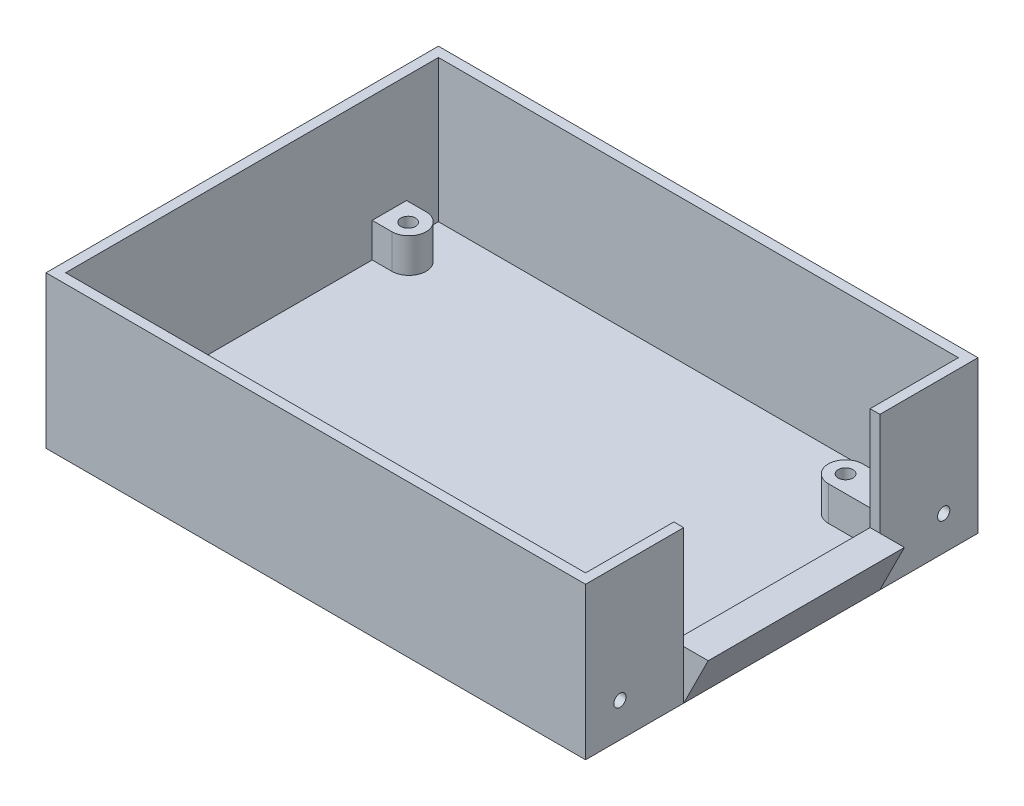
from build123d import *

# Parameters (mm, degrees)
SKETCH5_W            = 110
SKETCH5_H            = 80
BOSS_EXTRUDE8_DEPTH  = 2
SKETCH9_R            = 3.5
BOSS_EXTRUDE11_DEPTH = 7
SKETCH11_R           = 1.5
CUT_EXTRUDE1_DEPTH   = 7
SKETCH12_W           = 110
SKETCH12_H           = 80
SKETCH12_W_2         = 106
SKETCH12_H_2         = 76
BOSS_EXTRUDE12_DEPTH = 29
BOSS_EXTRUDE14_DEPTH = 7
BOSS_EXTRUDE15_DEPTH = 7
CUT_EXTRUDE2_REACH   = 112
SKETCH16_W           = 40
SKETCH16_H           = 21
BOSS_EXTRUDE16_DEPTH = 7
BOSS_EXTRUDE17_DEPTH = 7
BOSS_EXTRUDE18_DEPTH = 40
CUT_EXTRUDE4_REACH   = 112
SKETCH23_R           = 1.25
CUT_EXTRUDE5_REACH   = 112
SKETCH24_R           = 1.25


with BuildPart() as part:
    # Sketch5 → Boss-Extrude8 (new body)
    with BuildSketch(Plane(origin=(0, 0, 0), x_dir=(1, 0, 0), z_dir=(0, 1, 0))):
        with Locations((-25, 43.57615894)):
            Rectangle(SKETCH5_W, SKETCH5_H)
    extrude(amount=BOSS_EXTRUDE8_DEPTH)

    # Sketch9 → Boss-Extrude11 (add)
    with BuildSketch(Plane(origin=(0, 2, 0), x_dir=(1, 0, 0), z_dir=(0, 1, 0))):
        with Locations((-74, 15.57615894)):
            Circle(SKETCH9_R)
        with Locations((-74, 71.57615894)):
            Circle(SKETCH9_R)
        with Locations((15, 15.57615894)):
            Circle(SKETCH9_R)
        with Locations((15, 71.57615894)):
            Circle(SKETCH9_R)
    extrude(amount=BOSS_EXTRUDE11_DEPTH)

    # Sketch11 → Cut-Extrude1 (cut)
    with BuildSketch(Plane(origin=(0, 9, 0), x_dir=(1, 0, 0), z_dir=(0, 1, 0))):
        with Locations((-74, 15.57615894)):
            Circle(SKETCH11_R)
        with Locations((-74, 71.405276361)):
            Circle(SKETCH11_R)
        with Locations((15, 71.57615894)):
            Circle(SKETCH11_R)
        with Locations((15, 15.57615894)):
            Circle(SKETCH11_R)
    extrude(amount=-CUT_EXTRUDE1_DEPTH, mode=Mode.SUBTRACT)

    # Sketch12 → Boss-Extrude12 (add)
    with BuildSketch(Plane(origin=(0, 2, 0), x_dir=(1, 0, 0), z_dir=(0, 1, 0))):
        with Locations((-25, 43.57615894)):
            Rectangle(SKETCH12_W, SKETCH12_H)
        with Locations((-25, 43.57615894)):
            Rectangle(SKETCH12_W_2, SKETCH12_H_2, mode=Mode.SUBTRACT)
    extrude(amount=BOSS_EXTRUDE12_DEPTH)

    # Sketch14 → Boss-Extrude14 (add)
    with BuildSketch(Plane(origin=(0, 2, 0), x_dir=(1, 0, 0), z_dir=(0, 1, 0))):
        Polygon((-74, 12.07615894), (-78, 12.07615894), (-78, 19.07615894), (-74, 19.07615894), (-77.5, 15.57615894), align=None)
    extrude(amount=BOSS_EXTRUDE14_DEPTH)

    # Sketch15 → Boss-Extrude15 (add)
    with BuildSketch(Plane(origin=(0, 2, 0), x_dir=(1, 0, 0), z_dir=(0, 1, 0))):
        Polygon((-74, 75.07615894), (-78, 75.07615894), (-78, 68.07615894), (-74, 68.07615894), (-77.5, 71.57615894), align=None)
    extrude(amount=BOSS_EXTRUDE15_DEPTH)

    # Sketch16 → Cut-Extrude2 (cut, up to next)
    with BuildSketch(Plane(origin=(30, 0, 0), x_dir=(0, 0, -1), z_dir=(1, 0, 0)), mode=Mode.PRIVATE) as cut_extrude2_sk1:
        with Locations((43.57615894, 20.5)):
            Rectangle(SKETCH16_W, SKETCH16_H)
    cut_extrude2_tool1 = extrude(cut_extrude2_sk1.sketch, amount=-CUT_EXTRUDE2_REACH, mode=Mode.PRIVATE) & part.part
    add(cut_extrude2_tool1.solids().sort_by_distance((30, 20.5, -43.576159))[0], mode=Mode.SUBTRACT)

    # Sketch17 → Boss-Extrude16 (add)
    with BuildSketch(Plane(origin=(0, 2, 0), x_dir=(1, 0, 0), z_dir=(0, 1, 0))):
        Polygon((15, 75.07615894), (28, 75.07615894), (28, 68.07615894), (15, 68.07615894), (18.5, 71.57615894), align=None)
    extrude(amount=BOSS_EXTRUDE16_DEPTH)

    # Sketch18 → Boss-Extrude17 (add)
    with BuildSketch(Plane(origin=(0, 2, 0), x_dir=(1, 0, 0), z_dir=(0, 1, 0))):
        Polygon((15, 19.07615894), (28, 19.07615894), (28, 12.07615894), (15, 12.07615894), (18.5, 15.57615894), align=None)
    extrude(amount=BOSS_EXTRUDE17_DEPTH)

    # Sketch22 → Boss-Extrude18 (add)
    with BuildSketch(Plane.XY.offset(-63.57615894)):
        Polygon((30, 10), (35, 10), (30, 0), align=None)
    extrude(amount=BOSS_EXTRUDE18_DEPTH)

    # Sketch23 → Cut-Extrude4 (cut, up to next)
    with BuildSketch(Plane(origin=(30, 0, 0), x_dir=(0, 0, -1), z_dir=(1, 0, 0)), mode=Mode.PRIVATE) as cut_extrude4_sk1:
        with Locations((10.57615894, 7)):
            Circle(SKETCH23_R)
    cut_extrude4_tool1 = extrude(cut_extrude4_sk1.sketch, amount=-CUT_EXTRUDE4_REACH, mode=Mode.PRIVATE) & part.part
    add(cut_extrude4_tool1.solids().sort_by_distance((30, 7, -10.576159))[0], mode=Mode.SUBTRACT)

    # Sketch24 → Cut-Extrude5 (cut, up to next)
    with BuildSketch(Plane(origin=(30, 0, 0), x_dir=(0, 0, -1), z_dir=(1, 0, 0)), mode=Mode.PRIVATE) as cut_extrude5_sk1:
        with Locations((76.57615894, 7)):
            Circle(SKETCH24_R)
    cut_extrude5_tool1 = extrude(cut_extrude5_sk1.sketch, amount=-CUT_EXTRUDE5_REACH, mode=Mode.PRIVATE) & part.part
    add(cut_extrude5_tool1.solids().sort_by_distance((30, 7, -76.576159))[0], mode=Mode.SUBTRACT)


solid = part.part
